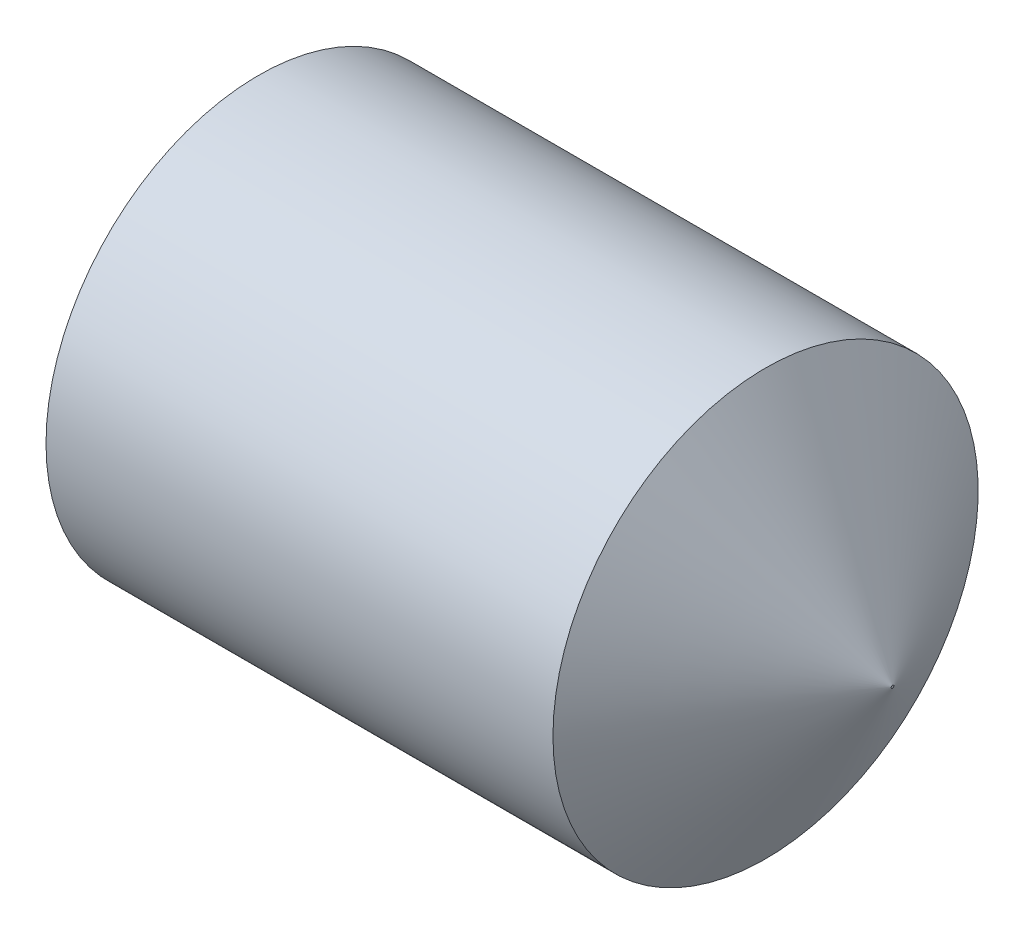
from build123d import *

# Parameters (mm, degrees)
HEX_2_DEPTH = 1


with BuildPart() as part:
    # BodySke → BaseBody (revolve)
    with BuildSketch(Plane.XY):
        Polygon((0, 0), (0, 0.601), (0.114892704, 0.8), (2.022315808, 0.8), (2.5, 0.005), (2.5, 0), align=None)
    revolve(axis=Axis((-12.7, 0, 0), (1, 0, 0)))

    # Sketch2 → Hex 2 (cut)
    with BuildSketch(Plane.ZY):
        Polygon((0.202072594, 0.35), (-0.202072594, 0.35), (-0.404145188, 0), (-0.202072594, -0.35), (0.202072594, -0.35), (0.404145188, 0), align=None)
    extrude(amount=-HEX_2_DEPTH, mode=Mode.SUBTRACT)


solid = part.part
